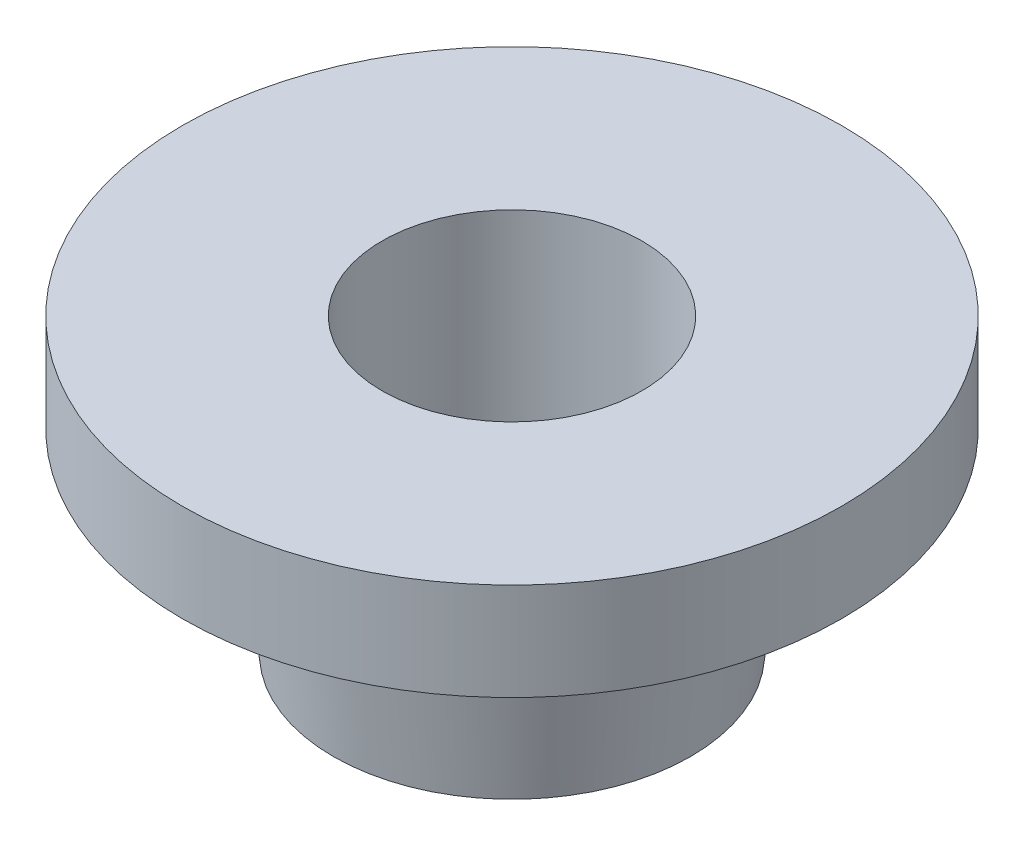
from build123d import *


with BuildPart() as part:
    # Sketch1 → Revolve1 (revolve)
    with BuildSketch(Plane.XY):
        Polygon((-4, 9), (-10.15, 9), (-10.15, 6), (-6.15, 6), (-5.5, 0), (-4, 0), align=None)
    revolve(axis=Axis((0, 0, 0), (0, 1, 0)))


solid = part.part
